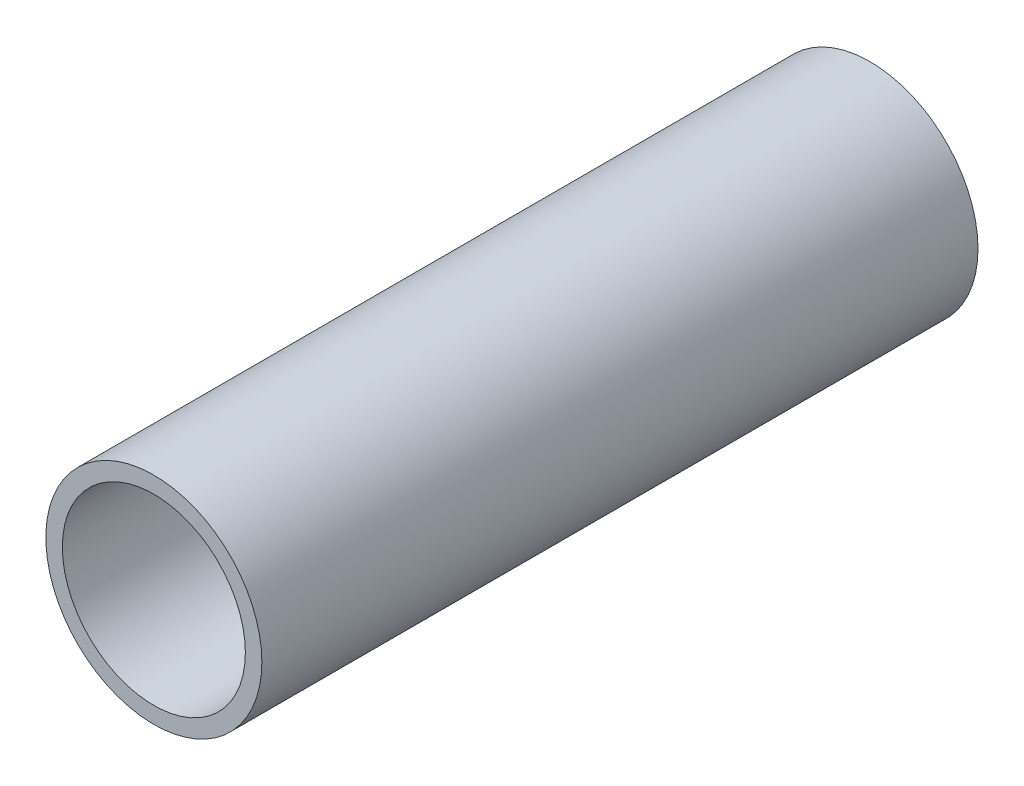
from build123d import *

# Parameters (mm, degrees)
SKETCH1_R           = 24.13
SKETCH1_R_2         = 20.447
EXTRUDE_THIN1_DEPTH = 80


with BuildPart() as part:
    # Sketch1 → Extrude-Thin1 (new body, symmetric)
    with BuildSketch(Plane.XY):
        Circle(SKETCH1_R)
        Circle(SKETCH1_R_2, mode=Mode.SUBTRACT)
    extrude(amount=EXTRUDE_THIN1_DEPTH, both=True)


solid = part.part
